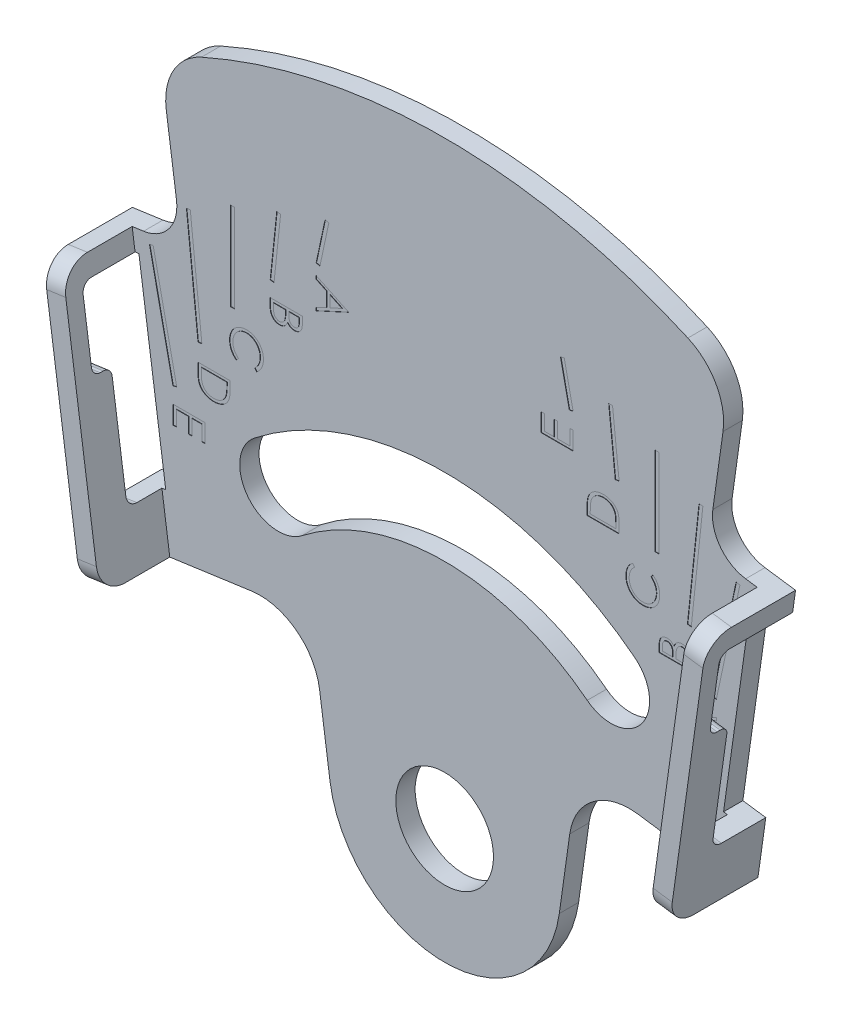
from build123d import *
from OCP.BRepFilletAPI import BRepFilletAPI_MakeFillet

# Parameters (mm, degrees)
SKETCH1_R          = 3.2131
EXTRUDE1_DEPTH     = 1.27
EXTRUDE2_DEPTH     = 4.5974
FILLET1_R          = 1.651
CUT_EXTRUDE1_DEPTH = 1.524
FILLET2_R1         = 0.635
FILLET2_R2         = 0.508
SKETCH4_W          = 0.254
SKETCH4_H          = 5.7912
CUT_EXTRUDE2_DEPTH = 0.0254
CUT_EXTRUDE3_DEPTH = 0.0254
CUT_EXTRUDE4_DEPTH = 0.0254


with BuildPart() as part:
    # Sketch1 → Extrude1 (new body)
    with BuildSketch(Plane.XY):
        with BuildLine():
            Line((21.821769044, 23.865251723), (19.809544328, 24.148051464))
            ThreePointArc((19.809544328, 24.148051464), (18.134509809, 25.1347222), (17.64776311, 27.016832035))
            Line((17.64776311, 27.016832035), (18.319649914, 31.79755506))
            ThreePointArc((18.319649914, 31.79755506), (17.8612339, 34.270332558), (16.006820778, 35.969133832))
            ThreePointArc((16.006820778, 35.969133832), (0, 39.37), (-16.006820778, 35.969133832))
            ThreePointArc((-16.006820778, 35.969133832), (-17.8612339, 34.270332558), (-18.319649914, 31.79755506))
            Line((-18.319649914, 31.79755506), (-17.64776311, 27.016832035))
            ThreePointArc((-17.64776311, 27.016832035), (-18.134509809, 25.1347222), (-19.809544328, 24.148051464))
            Line((-19.809544328, 24.148051464), (-21.821769044, 23.865251723))
            Line((-21.821769044, 23.865251723), (-19.347271309, 6.258285461))
            Line((-19.347271309, 6.258285461), (-12.706929747, 7.191524607))
            ThreePointArc((-12.706929747, 7.191524607), (-9.770838404, 6.432199756), (-8.231632056, 3.819145906))
            Line((-8.231632056, 3.819145906), (-7.545842684, -1.060499029))
            ThreePointArc((-7.545842684, -1.060499029), (0, -7.62), (7.545842684, -1.060499029))
            Line((7.545842684, -1.060499029), (8.231632056, 3.819145906))
            ThreePointArc((8.231632056, 3.819145906), (9.770838404, 6.432199756), (12.706929747, 7.191524607))
            Line((12.706929747, 7.191524607), (19.347271309, 6.258285461))
            Line((19.347271309, 6.258285461), (21.821769044, 23.865251723))
        make_face()
        Circle(SKETCH1_R, mode=Mode.SUBTRACT)
        with BuildLine():
            ThreePointArc((9.382680884, 12.009283885), (0, 15.24), (-9.382680884, 12.009283885))
            ThreePointArc((-9.382680884, 12.009283885), (-12.948008345, 12.447051052), (-12.510241179, 16.012378513))
            ThreePointArc((-12.510241179, 16.012378513), (0, 20.32), (12.510241179, 16.012378513))
            ThreePointArc((12.510241179, 16.012378513), (12.948008345, 12.447051052), (9.382680884, 12.009283885))
        make_face(mode=Mode.SUBTRACT)
    extrude(amount=EXTRUDE1_DEPTH)

    # Sketch2 → Extrude2 (add)
    with BuildSketch(Plane.XY.offset(1.27)):
        Polygon((-21.821769044, 23.865251723), (-19.347271309, 6.258285461), (-18.089630861, 6.435035299), (-20.564128596, 24.042001561), align=None)
        Polygon((19.347271309, 6.258285461), (21.821769044, 23.865251723), (20.564128596, 24.042001561), (18.089630861, 6.435035299), align=None)
    extrude(amount=EXTRUDE2_DEPTH)

    # Fillet1
    fillet1_edges = [part.edges().sort_by_distance(p)[0] for p in [
        (21.19294882, 23.953626642, 5.8674),
        (18.718451085, 6.34666038, 5.8674),
        (-21.19294882, 23.953626642, 5.8674),
        (-18.718451085, 6.34666038, 5.8674),
    ]]
    fillet(fillet1_edges, radius=FILLET1_R)

    # Sketch3 → Cut-Extrude1 (cut)
    with BuildSketch(Plane(origin=(18.110022441, -2.54519767, 0), x_dir=(0, 0, -1), z_dir=(0.9902680687415726, -0.13917310096005042, 0))):
        Polygon((0, 25.2984), (-4.7752, 25.2984), (-4.7752, 20.2184), (-3.556, 20.2184), (-3.556, 12.5984), (0, 12.5984), align=None)
    cut_extrude1 = extrude(amount=-CUT_EXTRUDE1_DEPTH, mode=Mode.SUBTRACT)

    # Mirror1: Cut-Extrude1 across plane
    add(cut_extrude1.mirror(Plane(origin=(0, 0, 0), x_dir=(0, 0, 1), z_dir=(1, 0, 0))), mode=Mode.SUBTRACT)

    # Fillet2: one fillet with a radius per group of edges: ONE call of the kernel's fillet builder (fillet() takes one radius for all edges)
    fillet2_edges_1 = [part.edges().sort_by_distance(p)[0] for p in [
        (21.002058995, 22.595374959, 4.7752),
        (19.234560613, 10.018970486, 3.556),
        (-21.002058995, 22.595374959, 4.7752),
        (-19.234560613, 10.018970486, 3.556),
    ]]
    fillet2_edges_2 = [part.edges().sort_by_distance(p)[0] for p in [
        (20.295059642, 17.56481317, 3.556),
        (20.295059642, 17.56481317, 4.7752),
        (-20.295059642, 17.56481317, 3.556),
        (-20.295059642, 17.56481317, 4.7752),
    ]]
    fillet2 = BRepFilletAPI_MakeFillet(part.part.solid().wrapped)
    for e in fillet2_edges_1:
        fillet2.Add(FILLET2_R1, e.wrapped)
    for e in fillet2_edges_2:
        fillet2.Add(FILLET2_R2, e.wrapped)
    add(Compound.cast(fillet2.Shape()), mode=Mode.REPLACE)

    # Sketch4 → Cut-Extrude2 (cut)
    with BuildSketch(Plane.XY.offset(1.27)):
        Polygon((-7.871224745, 30.765649695), (-8.455424745, 28.017204785), (-8.206975255, 27.964395215), (-7.622775255, 30.712840125), align=None)
        Polygon((-11.048304281, 29.648577686), (-11.480104281, 25.540275115), (-11.227495719, 25.513724885), (-10.795695719, 29.622027456), align=None)
        with Locations((-13.97, 25.6032)):
            Rectangle(SKETCH4_W, SKETCH4_H)
        Polygon((-16.991904281, 26.870870599), (-16.229904281, 19.620924885), (-15.977295719, 19.647475115), (-16.739295719, 26.897420829), align=None)
        Polygon((-19.428224745, 23.595149107), (-17.878824745, 16.305795215), (-17.630375255, 16.358604785), (-19.179775255, 23.647958676), align=None)
    cut_extrude2 = extrude(amount=-CUT_EXTRUDE2_DEPTH, mode=Mode.SUBTRACT)

    # Sketch5 → Cut-Extrude3 (cut)
    # profile 1 of 5: a face of its own
    with BuildSketch(Plane.XY.offset(1.27)):
        Polygon((-6.338758079, 26.260368492), (-8.455424745, 25.283445415), (-8.455424745, 25.489939138), (-7.777005942, 25.802859811), (-7.777005942, 26.762398406), (-8.455424745, 27.084223326), (-8.455424745, 27.291565073), (-6.338758079, 26.287505244), align=None)
        Polygon((-6.751321513, 26.276056927), (-7.559911925, 26.659363551), (-7.559911925, 25.902926585), align=None, mode=Mode.SUBTRACT)
    # profile 2 of 5: a face of its own
    with BuildSketch(Plane.XY.offset(1.27)):
        with BuildLine():
            Line((-9.363437614, 24.527078991), (-9.363437614, 24.114091544))
            add(Edge.make_bspline(
                [(-9.363437614, 24.114091544), (-9.363543901, 24.093875274), (-9.363749912, 24.054691111), (-9.366944949, 23.997710782), (-9.371301454, 23.944341263), (-9.378213938, 23.894567077), (-9.38655468, 23.848411224), (-9.396655302, 23.805734605), (-9.408766635, 23.766672929), (-9.428026053, 23.720038084), (-9.456645302, 23.666867018), (-9.498935434, 23.609294656), (-9.55066221, 23.560064474), (-9.609011244, 23.517618463), (-9.673198116, 23.483872071), (-9.741692958, 23.459458258), (-9.813612297, 23.444001829), (-9.862986981, 23.442412252), (-9.887940151, 23.441608905)],
                knots=[0, 0, 0, 0, 1.001505555, 1.941167018, 2.826882275, 3.653841531, 4.429895133, 5.150066043, 5.825578002, 6.45369114, 7.647487171, 8.808567382, 9.977351308, 11.170798116, 12.373658725, 13.556498008, 14.765093433, 16, 16, 16, 16], degree=3))
            add(Edge.make_bspline(
                [(-9.887940151, 23.441608905), (-9.911319705, 23.442257264), (-9.957262733, 23.443531351), (-10.024351251, 23.456129541), (-10.088476908, 23.474886448), (-10.148849168, 23.502115936), (-10.204692117, 23.537141483), (-10.255673883, 23.579290687), (-10.300558964, 23.629474823), (-10.325547559, 23.667134352), (-10.338240632, 23.686263686)],
                knots=[0, 0, 0, 0, 1.044266239, 2.052081639, 3.041743201, 4.026043445, 5.00270663, 5.980942822, 6.97441044, 8, 8, 8, 8], degree=3))
            add(Edge.make_bspline(
                [(-10.338240632, 23.686263686), (-10.347465198, 23.662214067), (-10.365114077, 23.616201189), (-10.396486869, 23.55283586), (-10.430224884, 23.498023445), (-10.467263493, 23.45170361), (-10.507686428, 23.412686317), (-10.550684242, 23.377647979), (-10.598373779, 23.348293707), (-10.649397111, 23.323075913), (-10.703396132, 23.303229774), (-10.760123883, 23.289187328), (-10.818946046, 23.280558928), (-10.859039327, 23.27938236), (-10.879279628, 23.278788392)],
                knots=[0, 0, 0, 0, 1.272302504, 2.434229863, 3.488457646, 4.447234501, 5.35599188, 6.26022912, 7.18267843, 8.11661068, 9.06895546, 10.019249207, 11.000057067, 12, 12, 12, 12], degree=3))
            add(Edge.make_bspline(
                [(-10.879279628, 23.278788392), (-10.899942333, 23.279379337), (-10.940596785, 23.280542037), (-11.000321802, 23.289114896), (-11.057390024, 23.303644422), (-11.112207215, 23.323608783), (-11.164463091, 23.349812835), (-11.214812111, 23.381015031), (-11.261913013, 23.418992058), (-11.306885908, 23.461322831), (-11.347298138, 23.509266984), (-11.383276244, 23.560987468), (-11.413000285, 23.617228193), (-11.437657103, 23.677117014), (-11.456766012, 23.741051895), (-11.470032302, 23.808795779), (-11.478991958, 23.880363389), (-11.479727215, 23.929476307), (-11.480104281, 23.954663125)],
                knots=[0, 0, 0, 0, 0.978404568, 1.925038397, 2.85041836, 3.763147166, 4.682162379, 5.614488577, 6.562659439, 7.54271123, 8.535210642, 9.526693784, 10.520907202, 11.541451354, 12.589717429, 13.675358278, 14.807842563, 16, 16, 16, 16], degree=3))
            Line((-11.480104281, 23.954663125), (-11.480104281, 24.527078991))
            Line((-11.480104281, 24.527078991), (-9.363437614, 24.527078991))
        make_face()
        with BuildLine():
            Line((-9.580531631, 24.337121726), (-10.258950435, 24.337121726))
            Line((-10.258950435, 24.337121726), (-10.258950435, 24.209494188))
            add(Edge.make_bspline(
                [(-10.258950435, 24.209494188), (-10.258710589, 24.190837844), (-10.258247158, 24.154789985), (-10.256877809, 24.102448271), (-10.253211478, 24.053984273), (-10.249333728, 24.009230994), (-10.243362786, 23.96848839), (-10.236056031, 23.931620064), (-10.228396025, 23.898294825), (-10.21533244, 23.859880972), (-10.196221582, 23.816320173), (-10.165865692, 23.77017786), (-10.13069178, 23.7288392), (-10.089357172, 23.69432194), (-10.044228937, 23.665839167), (-9.995303052, 23.646831001), (-9.944489568, 23.633348758), (-9.909514088, 23.632166453), (-9.891756257, 23.63156617)],
                knots=[0, 0, 0, 0, 1.156481963, 2.23455883, 3.244418989, 4.168404366, 5.01828131, 5.794834307, 6.498111525, 7.13526334, 8.307595709, 9.435046769, 10.546766856, 11.659452936, 12.760769924, 13.837671619, 14.902137667, 16, 16, 16, 16], degree=3))
            add(Edge.make_bspline(
                [(-9.891756257, 23.63156617), (-9.880002758, 23.631866397), (-9.856946984, 23.632455324), (-9.823466439, 23.637815263), (-9.791575037, 23.645592585), (-9.762006262, 23.657743136), (-9.733919682, 23.672435664), (-9.70856281, 23.691547976), (-9.684546448, 23.713132256), (-9.662752414, 23.738480893), (-9.643224875, 23.767471146), (-9.626042354, 23.800379239), (-9.612488289, 23.837598112), (-9.600329572, 23.878283869), (-9.591892747, 23.923087649), (-9.584838438, 23.971571659), (-9.581252538, 24.024147202), (-9.580777293, 24.060520563), (-9.580531631, 24.079322581)],
                knots=[0, 0, 0, 0, 0.911752476, 1.788502045, 2.626783689, 3.45400582, 4.26402138, 5.080402872, 5.911472738, 6.767166405, 7.66795952, 8.620018292, 9.640966946, 10.73819047, 11.913090943, 13.176185384, 14.540321519, 16, 16, 16, 16], degree=3))
            Line((-9.580531631, 24.079322581), (-9.580531631, 24.337121726))
        make_face(mode=Mode.SUBTRACT)
        with BuildLine():
            Line((-10.476044452, 24.337121726), (-11.263010264, 24.337121726))
            Line((-11.263010264, 24.337121726), (-11.263010264, 24.066602228))
            add(Edge.make_bspline(
                [(-11.263010264, 24.066602228), (-11.262778998, 24.047238305), (-11.262333265, 24.009916897), (-11.260862246, 23.956033145), (-11.257586505, 23.906225942), (-11.252246174, 23.860466626), (-11.246697104, 23.818352391), (-11.239016923, 23.780301642), (-11.230285486, 23.746256046), (-11.216773174, 23.706784331), (-11.195817389, 23.662308105), (-11.164014742, 23.614411688), (-11.126625688, 23.571402671), (-11.082807094, 23.535298756), (-11.035522587, 23.505485558), (-10.985019479, 23.484575823), (-10.932838472, 23.471131163), (-10.897168516, 23.469542427), (-10.879279628, 23.468745657)],
                knots=[0, 0, 0, 0, 1.159821618, 2.235403267, 3.228114831, 4.14795534, 4.994323282, 5.771256229, 6.471395042, 7.097801288, 8.267864287, 9.404187171, 10.531774336, 11.667624178, 12.792825787, 13.866573821, 14.930062559, 16, 16, 16, 16], degree=3))
            add(Edge.make_bspline(
                [(-10.879279628, 23.468745657), (-10.868094113, 23.468908515), (-10.845903507, 23.469231602), (-10.813318368, 23.474287376), (-10.781613369, 23.48134051), (-10.751267933, 23.491554055), (-10.721788277, 23.504432508), (-10.69368789, 23.520594477), (-10.666294881, 23.53925849), (-10.631703718, 23.568455172), (-10.591835258, 23.610882178), (-10.552806893, 23.671184494), (-10.52132995, 23.739746765), (-10.507965088, 23.789474959), (-10.501061145, 23.815163259)],
                knots=[0, 0, 0, 0, 0.723503378, 1.435336582, 2.130201219, 2.824764462, 3.504949994, 4.209866579, 4.920640069, 5.648298893, 7.13757748, 8.670694625, 10.280166878, 12, 12, 12, 12], degree=3))
            add(Edge.make_bspline(
                [(-10.501061145, 23.815163259), (-10.498971501, 23.825461798), (-10.494440723, 23.847791154), (-10.489661146, 23.88420259), (-10.48537371, 23.925910813), (-10.482285558, 23.972737555), (-10.478970481, 24.024869052), (-10.477727125, 24.082288556), (-10.476209544, 24.14503666), (-10.47610089, 24.188574958), (-10.476044452, 24.211190235)],
                knots=[0, 0, 0, 0, 0.634452549, 1.375623993, 2.216454381, 3.166361212, 4.209414599, 5.370755378, 6.634280627, 8, 8, 8, 8], degree=3))
            Line((-10.476044452, 24.211190235), (-10.476044452, 24.337121726))
        make_face(mode=Mode.SUBTRACT)
    # profile 3 of 5: a face of its own
    with BuildSketch(Plane.XY.offset(1.27)):
        with BuildLine():
            Line((-12.368728098, 19.853290674), (-12.495931624, 20.01950328))
            add(Edge.make_bspline(
                [(-12.495931624, 20.01950328), (-12.481800776, 20.031360175), (-12.453729593, 20.054914107), (-12.414311488, 20.092808006), (-12.377381544, 20.132299952), (-12.342763836, 20.173374849), (-12.311668935, 20.21677203), (-12.28247641, 20.261440228), (-12.256309731, 20.308126665), (-12.224582115, 20.372686047), (-12.191473726, 20.457139746), (-12.163713201, 20.563453767), (-12.146041347, 20.674434289), (-12.144127371, 20.750149028), (-12.143153846, 20.788660599)],
                knots=[0, 0, 0, 0, 0.757959112, 1.505699292, 2.245454638, 2.979532153, 3.711538275, 4.438200793, 5.171680507, 5.909471876, 7.393775596, 8.890124382, 10.418191784, 12, 12, 12, 12], degree=3))
            add(Edge.make_bspline(
                [(-12.143153846, 20.788660599), (-12.14339925, 20.809877384), (-12.143887779, 20.852114042), (-12.150287506, 20.914800496), (-12.159385989, 20.976435128), (-12.172557933, 21.03678874), (-12.189706608, 21.095741498), (-12.209817428, 21.153742277), (-12.234843301, 21.210107983), (-12.262481038, 21.265516963), (-12.293706601, 21.318600035), (-12.327754856, 21.368836383), (-12.364291624, 21.415996502), (-12.403222593, 21.460211072), (-12.445031598, 21.500995186), (-12.489226803, 21.539002469), (-12.536340155, 21.573547942), (-12.58548808, 21.605480499), (-12.636742818, 21.633894763), (-12.689781933, 21.658431856), (-12.744402638, 21.679462185), (-12.800716826, 21.69625724), (-12.858502887, 21.709504549), (-12.917883457, 21.718656392), (-12.978743275, 21.724998547), (-13.019993614, 21.725482583), (-13.040786725, 21.725726571)],
                knots=[0, 0, 0, 0, 1.055000685, 2.100209969, 3.131349012, 4.153242145, 5.170189196, 6.184191144, 7.204341339, 8.235672124, 9.263040994, 10.265373269, 11.252624173, 12.22887325, 13.193405896, 14.155809299, 15.126090485, 16.097288279, 17.069732292, 18.038585918, 19.002221264, 19.978698174, 20.959418239, 21.948869816, 22.966084182, 24, 24, 24, 24], degree=3))
            add(Edge.make_bspline(
                [(-13.040786725, 21.725726571), (-13.072071857, 21.724963471), (-13.133496063, 21.723465225), (-13.223466861, 21.710131233), (-13.309657935, 21.68986863), (-13.391530506, 21.659500162), (-13.470094132, 21.622053879), (-13.544019534, 21.574736938), (-13.614423838, 21.519935508), (-13.679643144, 21.456874311), (-13.739220492, 21.387686032), (-13.791683939, 21.313452771), (-13.835417225, 21.234359416), (-13.871809345, 21.151279264), (-13.899783652, 21.063572995), (-13.919477193, 20.971398329), (-13.932323655, 20.874955741), (-13.933553552, 20.809055199), (-13.934179487, 20.775516234)],
                knots=[0, 0, 0, 0, 1.029171465, 2.020641659, 2.987623507, 3.938342917, 4.889210282, 5.84687017, 6.821220943, 7.821438502, 8.827599549, 9.822697543, 10.807740252, 11.797342354, 12.80366471, 13.83203677, 14.896651826, 16, 16, 16, 16], degree=3))
            add(Edge.make_bspline(
                [(-13.934179487, 20.775516234), (-13.933158178, 20.738563656), (-13.931147996, 20.665832141), (-13.914118355, 20.559171478), (-13.886506185, 20.457066039), (-13.847863156, 20.359510332), (-13.797628434, 20.266779379), (-13.736730194, 20.178728065), (-13.664589155, 20.095282068), (-13.609505549, 20.045104197), (-13.581401709, 20.01950328)],
                knots=[0, 0, 0, 0, 1.028121516, 2.023589091, 2.998037872, 3.967518031, 4.937445131, 5.927275754, 6.942489185, 8, 8, 8, 8], degree=3))
            Line((-13.581401709, 20.01950328), (-13.7073332, 19.853290674))
            add(Edge.make_bspline(
                [(-13.7073332, 19.853290674), (-13.724592198, 19.866666846), (-13.759027524, 19.89335512), (-13.807572359, 19.93657047), (-13.853235958, 19.982094328), (-13.89564039, 20.030270727), (-13.935670892, 20.080523477), (-13.971985474, 20.133737755), (-14.005690336, 20.188994448), (-14.036143989, 20.246615267), (-14.063449031, 20.306411037), (-14.086500703, 20.368319528), (-14.106643564, 20.431816248), (-14.123105316, 20.496933175), (-14.135974479, 20.563887847), (-14.144572563, 20.63245054), (-14.150464488, 20.702765983), (-14.151001413, 20.750204386), (-14.151273504, 20.774244199)],
                knots=[0, 0, 0, 0, 0.986756325, 1.968786143, 2.935506311, 3.899499537, 4.868307269, 5.8376204, 6.809456583, 7.792545619, 8.781780509, 9.778496008, 10.776623214, 11.79151764, 12.812666265, 13.856269958, 14.913646641, 16, 16, 16, 16], degree=3))
            add(Edge.make_bspline(
                [(-14.151273504, 20.774244199), (-14.151115061, 20.797009655), (-14.15080176, 20.842025525), (-14.145726496, 20.908488103), (-14.138802132, 20.973191326), (-14.128375957, 21.035950266), (-14.116072475, 21.097107403), (-14.099579858, 21.156108328), (-14.081104886, 21.213533622), (-14.059390918, 21.269152571), (-14.034888274, 21.323012485), (-14.007195284, 21.374939647), (-13.976544823, 21.424910175), (-13.943612507, 21.473415358), (-13.90734052, 21.519738659), (-13.868232603, 21.564281505), (-13.826420567, 21.607293669), (-13.796270251, 21.633904817), (-13.781111245, 21.647284397)],
                knots=[0, 0, 0, 0, 1.114604814, 2.203992996, 3.262667896, 4.300477797, 5.318619304, 6.316056647, 7.298880507, 8.271930387, 9.238335007, 10.195173496, 11.151986948, 12.108099108, 13.064862484, 14.031167946, 15.010108607, 16, 16, 16, 16], degree=3))
            add(Edge.make_bspline(
                [(-13.781111245, 21.647284397), (-13.754779192, 21.668714524), (-13.702432991, 21.711316055), (-13.617593374, 21.765820635), (-13.529014981, 21.812476538), (-13.436232453, 21.850199118), (-13.339453985, 21.879688962), (-13.238630793, 21.900118542), (-13.133857038, 21.913394036), (-13.062593837, 21.914912163), (-13.026370326, 21.915683836)],
                knots=[0, 0, 0, 0, 0.994628077, 1.977248131, 2.950237994, 3.925870899, 4.908910175, 5.911660606, 6.938484602, 8, 8, 8, 8], degree=3))
            add(Edge.make_bspline(
                [(-13.026370326, 21.915683836), (-12.988298859, 21.914739107), (-12.913395624, 21.912880413), (-12.803442927, 21.897219187), (-12.698252052, 21.871719686), (-12.597418249, 21.836606703), (-12.501518452, 21.790283289), (-12.410147635, 21.734205052), (-12.323380405, 21.66782424), (-12.242326089, 21.591974535), (-12.168220932, 21.508774668), (-12.10302333, 21.419683008), (-12.04876573, 21.324866956), (-12.003410872, 21.225372908), (-11.968549706, 21.120455355), (-11.944145634, 21.010338276), (-11.928955759, 20.89522855), (-11.927035514, 20.816692702), (-11.926059829, 20.77678827)],
                knots=[0, 0, 0, 0, 1.032901378, 2.032168977, 3.007206631, 3.966850309, 4.924221947, 5.891988639, 6.871730993, 7.884084801, 8.900290346, 9.89161143, 10.874607481, 11.860025555, 12.854717796, 13.869097222, 14.917278314, 16, 16, 16, 16], degree=3))
            add(Edge.make_bspline(
                [(-11.926059829, 20.77678827), (-11.92635119, 20.752468041), (-11.92692791, 20.704328599), (-11.932559068, 20.633116971), (-11.941929494, 20.56378312), (-11.954767612, 20.49615937), (-11.97050284, 20.430000505), (-11.99110147, 20.365985265), (-12.01502153, 20.303765062), (-12.041868365, 20.243293298), (-12.07256045, 20.185227886), (-12.105895271, 20.129579395), (-12.142642307, 20.077019121), (-12.181586701, 20.026558401), (-12.224185229, 19.979333267), (-12.269050636, 19.933994981), (-12.317514236, 19.892109696), (-12.351625561, 19.866254035), (-12.368728098, 19.853290674)],
                knots=[0, 0, 0, 0, 1.096705196, 2.170817488, 3.219277236, 4.250701065, 5.274195539, 6.284202015, 7.28098643, 8.279664616, 9.266225751, 10.241373748, 11.203306326, 12.157093976, 13.114198862, 14.069774147, 15.032234603, 16, 16, 16, 16], degree=3))
        make_face()
    # profile 4 of 5: a face of its own
    with BuildSketch(Plane.XY.offset(1.27)):
        with BuildLine():
            Line((-16.229904281, 18.473822094), (-14.113237614, 18.473822094))
            Line((-14.113237614, 18.473822094), (-14.113237614, 18.046418248))
            add(Edge.make_bspline(
                [(-14.113237614, 18.046418248), (-14.113504534, 18.009244068), (-14.114020223, 17.937423746), (-14.117308643, 17.833640111), (-14.123067125, 17.737750701), (-14.131616833, 17.649809971), (-14.141878878, 17.569676638), (-14.154929638, 17.497479044), (-14.170278215, 17.433100187), (-14.183369175, 17.393506841), (-14.189559729, 17.374783632)],
                knots=[0, 0, 0, 0, 1.314317071, 2.539253741, 3.67075822, 4.709970291, 5.662644612, 6.526156501, 7.303037452, 8, 8, 8, 8], degree=3))
            add(Edge.make_bspline(
                [(-14.189559729, 17.374783632), (-14.198891643, 17.350293972), (-14.217343853, 17.301869996), (-14.252151559, 17.232922606), (-14.291590525, 17.168017155), (-14.335709364, 17.106800576), (-14.385769881, 17.050689725), (-14.439598896, 16.997422431), (-14.499396015, 16.949389905), (-14.563130944, 16.904664574), (-14.631450247, 16.865529179), (-14.702967352, 16.831016306), (-14.777548444, 16.801548338), (-14.855736361, 16.778555208), (-14.936780506, 16.759558966), (-15.02129438, 16.74681294), (-15.10878529, 16.738346271), (-15.16815823, 16.737499569), (-15.198283688, 16.737069957)],
                knots=[0, 0, 0, 0, 0.98467389, 1.947018643, 2.898343565, 3.837828625, 4.779009928, 5.722093987, 6.681368302, 7.658573986, 8.646467994, 9.637429229, 10.641859304, 11.657149908, 12.698561448, 13.768651538, 14.867827761, 16, 16, 16, 16], degree=3))
            add(Edge.make_bspline(
                [(-15.198283688, 16.737069957), (-15.224446348, 16.737450589), (-15.276002603, 16.738200664), (-15.351986697, 16.744927581), (-15.425710753, 16.75472381), (-15.496850983, 16.769820965), (-15.56588662, 16.788371728), (-15.632489822, 16.81126909), (-15.696709409, 16.838404681), (-15.758022267, 16.869887416), (-15.816326965, 16.904312389), (-15.870620181, 16.942057358), (-15.921934502, 16.980956389), (-15.967955384, 17.024008847), (-16.011314913, 17.068247938), (-16.049670295, 17.116019576), (-16.084692259, 17.165767391), (-16.116125172, 17.218449602), (-16.143396706, 17.275328922), (-16.166759744, 17.337181678), (-16.18599686, 17.404339136), (-16.202072503, 17.476698359), (-16.214817322, 17.554401132), (-16.223360992, 17.637518731), (-16.229138079, 17.725924888), (-16.229643921, 17.786630433), (-16.229904281, 17.817875913)],
                knots=[0, 0, 0, 0, 1.105818345, 2.179130549, 3.222742436, 4.24813173, 5.251184997, 6.243232575, 7.223185975, 8.195898781, 9.155064964, 10.083206407, 10.990357329, 11.874224667, 12.744762365, 13.607037788, 14.46074101, 15.315384698, 16.197310979, 17.123950979, 18.107232398, 19.148086642, 20.256146639, 21.433991621, 22.679261309, 24, 24, 24, 24], degree=3))
            Line((-16.229904281, 17.817875913), (-16.229904281, 18.473822094))
        make_face()
        with BuildLine():
            Line((-16.012810264, 18.283864829), (-16.012810264, 18.040906095))
            add(Edge.make_bspline(
                [(-16.012810264, 18.040906095), (-16.012660224, 18.005994175), (-16.012371644, 17.938845769), (-16.009839383, 17.842290694), (-16.00570164, 17.754068392), (-15.999910998, 17.674166337), (-15.992249502, 17.602629641), (-15.983707299, 17.539308802), (-15.973065031, 17.484411384), (-15.963418498, 17.451192153), (-15.958960771, 17.435841324)],
                knots=[0, 0, 0, 0, 1.375205317, 2.645023457, 3.804390687, 4.853969522, 5.800190428, 6.637939096, 7.370582563, 8, 8, 8, 8], degree=3))
            add(Edge.make_bspline(
                [(-15.958960771, 17.435841324), (-15.952156764, 17.416519764), (-15.938711265, 17.378338137), (-15.914176203, 17.323382626), (-15.885149244, 17.272103023), (-15.852693373, 17.223643804), (-15.816305942, 17.178318761), (-15.775876819, 17.136328966), (-15.731853115, 17.097375983), (-15.684069916, 17.061885918), (-15.632836152, 17.030173676), (-15.578804071, 17.002532944), (-15.522104078, 16.97908019), (-15.462531815, 16.960009712), (-15.400143431, 16.945231189), (-15.33510306, 16.934716443), (-15.26739041, 16.928179756), (-15.221336717, 16.927416375), (-15.197859676, 16.927027222)],
                knots=[0, 0, 0, 0, 0.998463025, 1.973077781, 2.929496817, 3.867873318, 4.813809365, 5.759268434, 6.706333209, 7.676553387, 8.657505312, 9.640584699, 10.632319813, 11.645628493, 12.686877747, 13.755137172, 14.855624085, 16, 16, 16, 16], degree=3))
            add(Edge.make_bspline(
                [(-15.197859676, 16.927027222), (-15.173104815, 16.927337969), (-15.124473671, 16.927948436), (-15.053115292, 16.935608685), (-14.984494131, 16.946826811), (-14.918560783, 16.96296321), (-14.855401031, 16.983810046), (-14.794658047, 17.008754975), (-14.737113536, 17.039042034), (-14.682280118, 17.073330188), (-14.630988211, 17.111824919), (-14.583838727, 17.154355468), (-14.540743837, 17.200473376), (-14.501634927, 17.249966099), (-14.467207496, 17.303525629), (-14.436581391, 17.360245633), (-14.410559631, 17.42092509), (-14.396724381, 17.463145943), (-14.389693276, 17.484602676)],
                knots=[0, 0, 0, 0, 1.122272916, 2.204715076, 3.251197285, 4.274229216, 5.279697671, 6.265416158, 7.248880903, 8.225321784, 9.195852973, 10.153576302, 11.101466393, 12.055578741, 13.010401466, 13.985536859, 14.976245305, 16, 16, 16, 16], degree=3))
            add(Edge.make_bspline(
                [(-14.389693276, 17.484602676), (-14.38478477, 17.502353131), (-14.374347939, 17.540095469), (-14.362963071, 17.601684097), (-14.352921302, 17.670998973), (-14.344419535, 17.74834784), (-14.338319108, 17.833642527), (-14.333740265, 17.926948634), (-14.330651968, 18.02830649), (-14.330441084, 18.098569261), (-14.330331631, 18.135036704)],
                knots=[0, 0, 0, 0, 0.674548936, 1.434276114, 2.292660221, 3.240891867, 4.284742987, 5.42552168, 6.663806718, 8, 8, 8, 8], degree=3))
            Line((-14.330331631, 18.135036704), (-14.330331631, 18.283864829))
            Line((-14.330331631, 18.283864829), (-16.012810264, 18.283864829))
        make_face(mode=Mode.SUBTRACT)
    # profile 5 of 5: a face of its own
    with BuildSketch(Plane.XY.offset(1.27)):
        Polygon((-15.762158079, 15.257465772), (-15.762158079, 14.063448678), (-15.979252096, 14.063448678), (-15.979252096, 15.067508507), (-16.630534147, 15.067508507), (-16.630534147, 14.063448678), (-16.847628164, 14.063448678), (-16.847628164, 15.067508507), (-17.661730728, 15.067508507), (-17.661730728, 14.063448678), (-17.878824745, 14.063448678), (-17.878824745, 15.257465772), align=None)
    extrude(amount=-CUT_EXTRUDE3_DEPTH, mode=Mode.SUBTRACT)

    # Mirror2: Cut-Extrude2 across plane
    add(cut_extrude2.mirror(Plane(origin=(0, 0, 0), x_dir=(0, 0, 1), z_dir=(1, 0, 0))), mode=Mode.SUBTRACT)

    # Sketch6 → Cut-Extrude4 (cut)
    # profile 1 of 5: a face of its own
    with BuildSketch(Plane.XY.offset(1.27)):
        Polygon((6.338758079, 25.745920499), (6.338758079, 26.939937593), (6.555852096, 26.939937593), (6.555852096, 25.935877764), (7.207134147, 25.935877764), (7.207134147, 26.939937593), (7.424228164, 26.939937593), (7.424228164, 25.935877764), (8.238330728, 25.935877764), (8.238330728, 26.939937593), (8.455424745, 26.939937593), (8.455424745, 25.745920499), align=None)
    # profile 2 of 5: a face of its own
    with BuildSketch(Plane.XY.offset(1.27)):
        with BuildLine():
            Line((11.480104281, 22.540913257), (9.363437614, 22.540913257))
            Line((9.363437614, 22.540913257), (9.363437614, 22.968317104))
            add(Edge.make_bspline(
                [(9.363437614, 22.968317104), (9.363705264, 23.005491206), (9.364222361, 23.077311378), (9.367501012, 23.181096049), (9.37330096, 23.27712242), (9.381749197, 23.365074673), (9.392122699, 23.445194263), (9.405125324, 23.517256849), (9.420479122, 23.58163505), (9.433569466, 23.621228474), (9.439759729, 23.639951719)],
                knots=[0, 0, 0, 0, 1.314313732, 2.53924729, 3.670748893, 4.714932338, 5.66265055, 6.526160246, 7.303039223, 8, 8, 8, 8], degree=3))
            add(Edge.make_bspline(
                [(9.439759729, 23.639951719), (9.449088726, 23.6644436), (9.467535169, 23.712871968), (9.502385216, 23.781787114), (9.541709646, 23.846884105), (9.586413426, 23.907643929), (9.635912798, 23.964219039), (9.68985414, 24.017251547), (9.749435735, 24.065433934), (9.813597066, 24.109516643), (9.881516046, 24.149273652), (9.953081442, 24.183828539), (10.027924861, 24.212527096), (10.105839512, 24.236350567), (10.186996352, 24.255126296), (10.271489981, 24.267936318), (10.358986442, 24.276385441), (10.418358617, 24.277234558), (10.448483688, 24.277665394)],
                knots=[0, 0, 0, 0, 0.984741985, 1.947153288, 2.898543998, 3.841229145, 4.778974371, 5.722123648, 6.681464302, 7.655713756, 8.646344578, 9.637374342, 10.639946623, 11.656849581, 12.698333139, 13.76849723, 14.867749466, 16, 16, 16, 16], degree=3))
            add(Edge.make_bspline(
                [(10.448483688, 24.277665394), (10.474646437, 24.277285018), (10.526202866, 24.276535448), (10.602185696, 24.269804866), (10.675914367, 24.260022028), (10.74703786, 24.244876308), (10.816179046, 24.226489823), (10.882602006, 24.202926532), (10.946912481, 24.175929958), (11.008254035, 24.144462199), (11.06633207, 24.109868849), (11.121122029, 24.072976078), (11.171408103, 24.032947188), (11.218508017, 23.990966912), (11.261163548, 23.946022902), (11.30015225, 23.898662345), (11.334821368, 23.848701185), (11.365715693, 23.795830148), (11.393343633, 23.739343127), (11.41638865, 23.677463322), (11.436347987, 23.610483842), (11.452225641, 23.538022722), (11.465031082, 23.460338409), (11.473556995, 23.377215403), (11.479339174, 23.288810796), (11.479844293, 23.228105031), (11.480104281, 23.196859438)],
                knots=[0, 0, 0, 0, 1.106010661, 2.179509527, 3.223302912, 4.248870533, 5.252098245, 6.246278179, 7.226402005, 8.199283979, 9.158616973, 10.083547221, 10.989831858, 11.874256832, 12.749262829, 13.607058236, 14.46581075, 15.317568432, 16.194266721, 17.121067875, 18.106207572, 19.147242834, 20.255495536, 21.43354536, 22.679031616, 24, 24, 24, 24], degree=3))
            Line((11.480104281, 23.196859438), (11.480104281, 22.540913257))
        make_face()
        with BuildLine():
            Line((11.263010264, 22.730870522), (11.263010264, 22.973829256))
            add(Edge.make_bspline(
                [(11.263010264, 22.973829256), (11.262860224, 23.008741176), (11.262571644, 23.075889583), (11.260039383, 23.172444657), (11.25590164, 23.260666959), (11.250110998, 23.340569014), (11.242449502, 23.41210571), (11.233907299, 23.475426549), (11.223265031, 23.530323967), (11.213618498, 23.563543198), (11.209160771, 23.578894027)],
                knots=[0, 0, 0, 0, 1.375205317, 2.645023457, 3.804390687, 4.853969522, 5.800190428, 6.637939096, 7.370582563, 8, 8, 8, 8], degree=3))
            add(Edge.make_bspline(
                [(11.209160771, 23.578894027), (11.202356259, 23.598215181), (11.188909759, 23.636396004), (11.164382012, 23.691357393), (11.135328066, 23.742615308), (11.103032158, 23.791062408), (11.06635669, 23.836013799), (11.026093624, 23.877993373), (10.982059009, 23.916949734), (10.934324248, 23.95228285), (10.883406968, 23.984286521), (10.829217117, 24.011760331), (10.772516523, 24.03568642), (10.712846162, 24.054631549), (10.650643386, 24.069568953), (10.585585647, 24.080039239), (10.517730515, 24.08653935), (10.471536502, 24.087314288), (10.448059676, 24.087708129)],
                knots=[0, 0, 0, 0, 0.998590647, 1.973329978, 2.929871262, 3.868367705, 4.809062953, 5.754642869, 6.701828697, 7.672172887, 8.647399344, 9.630604387, 10.631475358, 11.644913558, 12.679592956, 13.747988925, 14.855477812, 16, 16, 16, 16], degree=3))
            add(Edge.make_bspline(
                [(10.448059676, 24.087708129), (10.423304666, 24.087397713), (10.374673231, 24.086787896), (10.303316954, 24.079122956), (10.234688179, 24.067921825), (10.168782318, 24.051724072), (10.105470791, 24.031083017), (10.045103754, 24.0053234), (9.987043666, 23.975891683), (9.932630598, 23.94087395), (9.881169527, 23.902522615), (9.834025364, 23.859960755), (9.791090715, 23.81386457), (9.751696941, 23.764736828), (9.717428908, 23.711192963), (9.686775534, 23.654494302), (9.660761162, 23.593809063), (9.646924897, 23.551589004), (9.639893276, 23.530132675)],
                knots=[0, 0, 0, 0, 1.122418816, 2.205001699, 3.251619955, 4.274784885, 5.280384055, 6.268708349, 7.249350384, 8.229342522, 9.199999885, 10.157847722, 11.105861043, 12.055065948, 13.010012805, 13.98527497, 14.976112212, 16, 16, 16, 16], degree=3))
            add(Edge.make_bspline(
                [(9.639893276, 23.530132675), (9.63498477, 23.51238222), (9.624547939, 23.474639882), (9.613163071, 23.413051254), (9.603121302, 23.343736378), (9.594619535, 23.266387511), (9.588519108, 23.181092824), (9.583940265, 23.087786717), (9.580851968, 22.986428861), (9.580641084, 22.916166091), (9.580531631, 22.879698647)],
                knots=[0, 0, 0, 0, 0.674548936, 1.434276114, 2.292660221, 3.240891867, 4.284742987, 5.42552168, 6.663806718, 8, 8, 8, 8], degree=3))
            Line((9.580531631, 22.879698647), (9.580531631, 22.730870522))
            Line((9.580531631, 22.730870522), (11.263010264, 22.730870522))
        make_face(mode=Mode.SUBTRACT)
    # profile 3 of 5: a face of its own
    with BuildSketch(Plane.XY.offset(1.27)):
        with BuildLine():
            Line((12.368728098, 21.311706095), (12.495931624, 21.145493488))
            add(Edge.make_bspline(
                [(12.495931624, 21.145493488), (12.481800962, 21.133636472), (12.453730151, 21.110082299), (12.414309299, 21.072190186), (12.37738963, 21.032691558), (12.34273393, 20.991641371), (12.311735082, 20.948089628), (12.281978872, 20.903695775), (12.255926286, 20.856846785), (12.224099794, 20.792392553), (12.191612987, 20.707746656), (12.163671529, 20.601559632), (12.146052288, 20.490558113), (12.14413106, 20.414846269), (12.143153846, 20.37633617)],
                knots=[0, 0, 0, 0, 0.75789156, 1.505565099, 2.245254514, 2.979266606, 3.711207489, 4.440978832, 5.174393176, 5.91211879, 7.394186119, 8.890401545, 10.418332761, 12, 12, 12, 12], degree=3))
            add(Edge.make_bspline(
                [(12.143153846, 20.37633617), (12.143398147, 20.355119127), (12.143884482, 20.312881955), (12.150300477, 20.250199307), (12.159318209, 20.188687128), (12.172698762, 20.128385432), (12.189615535, 20.069370976), (12.209829954, 20.011257954), (12.234839779, 19.954887725), (12.262482421, 19.899480541), (12.293704631, 19.846394882), (12.327761169, 19.796166849), (12.364268755, 19.748976697), (12.403372216, 19.704797858), (12.444866051, 19.663545541), (12.489215128, 19.625738848), (12.535945342, 19.590872652), (12.585095499, 19.559145662), (12.636207842, 19.530584003), (12.689574192, 19.50656809), (12.744280808, 19.485592753), (12.800715522, 19.468734025), (12.85850324, 19.45549371), (12.91788336, 19.446339965), (12.9787433, 19.439998327), (13.019993623, 19.439514222), (13.040786725, 19.439270198)],
                knots=[0, 0, 0, 0, 1.054877232, 2.099964208, 3.13098259, 4.145888998, 5.169474743, 6.183358035, 7.203388855, 8.234598956, 9.261847606, 10.264062591, 11.251197969, 12.227332808, 13.196685059, 14.158975844, 15.123498106, 16.094582253, 17.066912473, 18.032714859, 19.002806091, 19.979168736, 20.95977404, 21.949109834, 22.966205168, 24, 24, 24, 24], degree=3))
            add(Edge.make_bspline(
                [(13.040786725, 19.439270198), (13.07207116, 19.440035087), (13.133493996, 19.441536846), (13.223474694, 19.454845438), (13.309759013, 19.475231593), (13.39176273, 19.505284656), (13.470169445, 19.543081151), (13.544028316, 19.590240755), (13.614421398, 19.645066561), (13.67964381, 19.708121011), (13.739220315, 19.77731112), (13.791683986, 19.851543896), (13.835417213, 19.930637379), (13.871809349, 20.013717497), (13.899783651, 20.101423776), (13.919477194, 20.193598439), (13.932323655, 20.290041028), (13.933553552, 20.355941569), (13.934179487, 20.389480534)],
                knots=[0, 0, 0, 0, 1.029159485, 2.020618137, 2.987588728, 3.942669054, 4.889339625, 5.846988364, 6.821327795, 7.821533711, 8.827683044, 9.822769455, 10.807800696, 11.797391277, 12.803701919, 13.832062008, 14.896664671, 16, 16, 16, 16], degree=3))
            add(Edge.make_bspline(
                [(13.934179487, 20.389480534), (13.933158178, 20.426433113), (13.931147996, 20.499164627), (13.914118355, 20.605825291), (13.886506185, 20.70793073), (13.847863156, 20.805486437), (13.797628434, 20.89821739), (13.736730194, 20.986268703), (13.664589155, 21.069714701), (13.609505549, 21.119892571), (13.581401709, 21.145493488)],
                knots=[0, 0, 0, 0, 1.028121516, 2.023589091, 2.998037872, 3.967518031, 4.937445131, 5.927275754, 6.942489185, 8, 8, 8, 8], degree=3))
            Line((13.581401709, 21.145493488), (13.7073332, 21.311706095))
            add(Edge.make_bspline(
                [(13.7073332, 21.311706095), (13.724591571, 21.298329436), (13.759025647, 21.271640191), (13.807579778, 21.22843206), (13.853208649, 21.182881233), (13.895684392, 21.134870623), (13.935182821, 21.08431561), (13.971725391, 21.031220832), (14.005118171, 20.975631612), (14.035791079, 20.917989487), (14.062797534, 20.858161633), (14.086729199, 20.796674741), (14.106541974, 20.733151809), (14.123301358, 20.668127559), (14.135251554, 20.60101473), (14.144767753, 20.532593459), (14.150413467, 20.462223346), (14.150984254, 20.41478988), (14.151273504, 20.390752569)],
                knots=[0, 0, 0, 0, 0.986911346, 1.969095443, 2.935967484, 3.900112155, 4.865124501, 5.834589912, 6.812044781, 7.795288262, 8.784678562, 9.777857908, 10.776141921, 11.791195789, 12.811324908, 13.855933174, 14.913475973, 16, 16, 16, 16], degree=3))
            add(Edge.make_bspline(
                [(14.151273504, 20.390752569), (14.151115061, 20.367987114), (14.15080176, 20.322971244), (14.145726496, 20.256508666), (14.138802132, 20.191805443), (14.128375957, 20.129046502), (14.116072475, 20.067889365), (14.099579858, 20.00888844), (14.081104886, 19.951463146), (14.059390918, 19.895844198), (14.034888274, 19.841984284), (14.007195284, 19.790057122), (13.976544823, 19.740086594), (13.943612507, 19.69158141), (13.90734052, 19.64525811), (13.868232603, 19.600715264), (13.826420567, 19.557703099), (13.796270251, 19.531091952), (13.781111245, 19.517712372)],
                knots=[0, 0, 0, 0, 1.114604814, 2.203992996, 3.262667896, 4.300477797, 5.318619304, 6.316056647, 7.298880507, 8.271930387, 9.238335007, 10.195173496, 11.151986948, 12.108099108, 13.064862484, 14.031167946, 15.010108607, 16, 16, 16, 16], degree=3))
            add(Edge.make_bspline(
                [(13.781111245, 19.517712372), (13.754778649, 19.496283642), (13.702431368, 19.45368489), (13.617599749, 19.39915973), (13.52910722, 19.352642101), (13.436441218, 19.314611034), (13.339565718, 19.285398737), (13.238636566, 19.264860593), (13.133855523, 19.25160736), (13.062593326, 19.250086165), (13.026370326, 19.249312933)],
                knots=[0, 0, 0, 0, 0.994611881, 1.977215934, 2.950189954, 3.921972279, 4.908960509, 5.911694611, 6.938501887, 8, 8, 8, 8], degree=3))
            add(Edge.make_bspline(
                [(13.026370326, 19.249312933), (12.988297266, 19.250253455), (12.913390897, 19.252103872), (12.803460935, 19.267825139), (12.698140803, 19.293115554), (12.59762711, 19.32903653), (12.501391179, 19.374578337), (12.410168164, 19.430837289), (12.323374671, 19.497159799), (12.242327655, 19.573025709), (12.168220523, 19.656221193), (12.103023438, 19.745313999), (12.048765702, 19.840129748), (12.00341088, 19.939623878), (11.968549704, 20.044541409), (11.944145634, 20.154658494), (11.928955759, 20.269768219), (11.927035514, 20.348304067), (11.926059829, 20.388208499)],
                knots=[0, 0, 0, 0, 1.032925535, 2.032216505, 3.007276963, 3.968222605, 4.92396291, 5.891752235, 6.871517503, 7.883894988, 8.900124299, 9.891468569, 10.874487609, 11.85992873, 12.854644235, 13.869047385, 14.917252991, 16, 16, 16, 16], degree=3))
            add(Edge.make_bspline(
                [(11.926059829, 20.388208499), (11.926351661, 20.4125286), (11.926929314, 20.46066779), (11.932553639, 20.531881265), (11.94194919, 20.601208326), (11.95467015, 20.668721884), (11.970689632, 20.734617127), (11.990655039, 20.798770775), (12.014425258, 20.861025731), (12.041569746, 20.921361771), (12.072093568, 20.979371595), (12.105636686, 21.035018783), (12.142029615, 21.088081485), (12.181644937, 21.138283906), (12.224154047, 21.185687465), (12.26905901, 21.230995352), (12.317512122, 21.272888697), (12.351624855, 21.298743276), (12.368728098, 21.311706095)],
                knots=[0, 0, 0, 0, 1.096622143, 2.170653093, 3.219033441, 4.250379162, 5.267604342, 6.275621678, 7.278284436, 8.271072515, 9.257558938, 10.232633088, 11.19973724, 12.157384997, 13.114417402, 14.069920322, 15.032307892, 16, 16, 16, 16], degree=3))
        make_face()
    # profile 4 of 5: a face of its own
    with BuildSketch(Plane.XY.offset(1.27)):
        with BuildLine():
            Line((14.113237614, 17.097456198), (14.113237614, 17.510443644))
            add(Edge.make_bspline(
                [(14.113237614, 17.510443644), (14.113342228, 17.530660233), (14.113544996, 17.569845014), (14.116762772, 17.62682101), (14.121040502, 17.680205539), (14.128216164, 17.729904263), (14.135656378, 17.776240564), (14.146576831, 17.818744032), (14.15863887, 17.857770686), (14.177197954, 17.90463371), (14.206020445, 17.957806231), (14.248766938, 18.014956743), (14.300016532, 18.064635454), (14.358419486, 18.106877085), (14.422669354, 18.140776892), (14.491383779, 18.16499164), (14.563406722, 18.180548116), (14.61278511, 18.182127891), (14.637740151, 18.182926283)],
                knots=[0, 0, 0, 0, 1.00128172, 1.940733171, 2.826250472, 3.653024905, 4.427672124, 5.149348099, 5.824709082, 6.450061444, 7.643590664, 8.808605388, 9.972104426, 11.165284501, 12.367876273, 13.557044126, 14.765369432, 16, 16, 16, 16], degree=3))
            add(Edge.make_bspline(
                [(14.637740151, 18.182926283), (14.661114717, 18.18226128), (14.707047942, 18.180954487), (14.774114731, 18.16861071), (14.837891328, 18.149019371), (14.898323147, 18.121943351), (14.954285247, 18.087057414), (15.005604271, 18.045259157), (15.050340643, 17.995038886), (15.075341387, 17.957393601), (15.088040632, 17.938271502)],
                knots=[0, 0, 0, 0, 1.044641374, 2.052818814, 3.038628718, 4.023282556, 5.005660861, 5.98021751, 6.974042014, 8, 8, 8, 8], degree=3))
            add(Edge.make_bspline(
                [(15.088040632, 17.938271502), (15.097275311, 17.962314772), (15.11494354, 18.008315504), (15.14613192, 18.071655739), (15.180177017, 18.126028362), (15.216781578, 18.172495514), (15.256819313, 18.212027033), (15.300615511, 18.246263614), (15.348134317, 18.275861805), (15.399201085, 18.301049661), (15.453382898, 18.320835036), (15.51001798, 18.335377013), (15.568889219, 18.343978908), (15.60884042, 18.345152338), (15.629079628, 18.345746796)],
                knots=[0, 0, 0, 0, 1.272586185, 2.434772614, 3.483318042, 4.437947805, 5.351807173, 6.25737843, 7.180033415, 8.1141739, 9.066731021, 10.025721652, 10.999834114, 12, 12, 12, 12], degree=3))
            add(Edge.make_bspline(
                [(15.629079628, 18.345746796), (15.649742535, 18.345156166), (15.690397383, 18.343994084), (15.750119525, 18.335416733), (15.807198311, 18.320903718), (15.861976634, 18.30087861), (15.914339643, 18.274922736), (15.964097644, 18.242878757), (16.011354158, 18.205196506), (16.056192586, 18.162609472), (16.097221158, 18.115149553), (16.132491893, 18.062845668), (16.162819699, 18.007130689), (16.187511517, 17.947292351), (16.206561238, 17.883483412), (16.219833654, 17.815739376), (16.228791593, 17.744171808), (16.229527092, 17.695058885), (16.229904281, 17.669872063)],
                knots=[0, 0, 0, 0, 0.978680899, 1.925582087, 2.851223405, 3.764209995, 4.683484765, 5.614004905, 6.562443559, 7.542772147, 8.539900013, 9.527881485, 10.525548727, 11.540192123, 12.58875426, 13.674701727, 14.807505862, 16, 16, 16, 16], degree=3))
            Line((16.229904281, 17.669872063), (16.229904281, 17.097456198))
            Line((16.229904281, 17.097456198), (14.113237614, 17.097456198))
        make_face()
        with BuildLine():
            Line((14.330331631, 17.287413463), (15.008750435, 17.287413463))
            Line((15.008750435, 17.287413463), (15.008750435, 17.415041))
            add(Edge.make_bspline(
                [(15.008750435, 17.415041), (15.008508576, 17.433697176), (15.008041257, 17.469744711), (15.006702606, 17.521947695), (15.002954267, 17.570404256), (14.999206998, 17.615030739), (14.993114289, 17.655756904), (14.985861853, 17.692492411), (14.978191898, 17.725814157), (14.965146721, 17.764239554), (14.945873564, 17.807832631), (14.915934158, 17.854274253), (14.880302484, 17.895406417), (14.838803893, 17.929723694), (14.793604629, 17.958057729), (14.745101501, 17.977906611), (14.694270572, 17.991139271), (14.659307691, 17.992352855), (14.641556257, 17.992969018)],
                knots=[0, 0, 0, 0, 1.156917035, 2.235399477, 3.236897345, 4.169954739, 5.01148057, 5.788325709, 6.491867502, 7.129259015, 8.302032419, 9.437271567, 10.542795419, 11.662606952, 12.764338259, 13.836858145, 14.901724648, 16, 16, 16, 16], degree=3))
            add(Edge.make_bspline(
                [(14.641556257, 17.992969018), (14.629806751, 17.992656168), (14.60675881, 17.992042479), (14.573051079, 17.986833771), (14.541378176, 17.978394282), (14.51143612, 17.96696494), (14.483969043, 17.951350762), (14.457664497, 17.933251878), (14.434097997, 17.910906236), (14.412134958, 17.885653676), (14.392478111, 17.856760244), (14.376195461, 17.82360343), (14.361437969, 17.787040388), (14.350513437, 17.746079143), (14.340907024, 17.701568426), (14.33487125, 17.652905545), (14.330987172, 17.600398866), (14.330555019, 17.564018333), (14.330331631, 17.545212608)],
                knots=[0, 0, 0, 0, 0.911708768, 1.788416306, 2.640049961, 3.452993646, 4.268229297, 5.087074648, 5.92553149, 6.781184137, 7.681934069, 8.628939405, 9.643570426, 10.73771997, 11.914765019, 13.176320755, 14.540391495, 16, 16, 16, 16], degree=3))
            Line((14.330331631, 17.545212608), (14.330331631, 17.287413463))
        make_face(mode=Mode.SUBTRACT)
        with BuildLine():
            Line((15.225844452, 17.287413463), (16.012810264, 17.287413463))
            Line((16.012810264, 17.287413463), (16.012810264, 17.55793296))
            add(Edge.make_bspline(
                [(16.012810264, 17.55793296), (16.012555112, 17.577294762), (16.01206334, 17.614612082), (16.010910033, 17.66853431), (16.006547248, 17.718381463), (16.002522598, 17.764310789), (15.99564062, 17.806200392), (15.989145822, 17.84437249), (15.979504759, 17.87820046), (15.966254251, 17.917787011), (15.945041833, 17.962035626), (15.914050691, 18.010391397), (15.875802838, 18.05255688), (15.832303148, 18.088752011), (15.785136209, 18.118621805), (15.73491864, 18.140056208), (15.682627077, 18.15337631), (15.64696471, 18.154983505), (15.629079628, 18.155789531)],
                knots=[0, 0, 0, 0, 1.160376723, 2.23647316, 3.230273494, 4.158083346, 4.997711197, 5.773399541, 6.476071462, 7.102777513, 8.27340052, 9.405620712, 10.53304798, 11.669441455, 12.787990954, 13.865552736, 14.929550474, 16, 16, 16, 16], degree=3))
            add(Edge.make_bspline(
                [(15.629079628, 18.155789531), (15.617895319, 18.155623065), (15.595707106, 18.155292818), (15.563104384, 18.150289658), (15.531507191, 18.14305167), (15.500783856, 18.133519033), (15.471450951, 18.120192919), (15.443395986, 18.103856221), (15.4160538, 18.085155967), (15.381039763, 18.056305012), (15.341198646, 18.013728364), (15.302673557, 17.953222194), (15.271102619, 17.884804397), (15.257755778, 17.83506567), (15.250861145, 17.809371929)],
                knots=[0, 0, 0, 0, 0.723302347, 1.434937762, 2.129609326, 2.821140842, 3.513216847, 4.209993937, 4.920569932, 5.655069131, 7.14393391, 8.6716197, 10.280644748, 12, 12, 12, 12], degree=3))
            add(Edge.make_bspline(
                [(15.250861145, 17.809371929), (15.248771642, 17.799073381), (15.244241168, 17.776744004), (15.23945889, 17.740332753), (15.235198306, 17.698763918), (15.232046797, 17.651941511), (15.22878922, 17.599806293), (15.227522352, 17.542246918), (15.226010895, 17.479498447), (15.225901352, 17.435960203), (15.225844452, 17.413344953)],
                knots=[0, 0, 0, 0, 0.634451884, 1.375622551, 2.216452059, 3.157844607, 4.20941857, 5.370758133, 6.634282058, 8, 8, 8, 8], degree=3))
            Line((15.225844452, 17.413344953), (15.225844452, 17.287413463))
        make_face(mode=Mode.SUBTRACT)
    # profile 5 of 5: a face of its own
    with BuildSketch(Plane.XY.offset(1.27)):
        Polygon((15.762158079, 14.303726236), (17.878824745, 15.280649313), (17.878824745, 15.07415559), (17.200405942, 14.761234917), (17.200405942, 13.801696322), (17.878824745, 13.479871402), (17.878824745, 13.272529655), (15.762158079, 14.276589484), align=None)
        Polygon((16.174721513, 14.288037801), (16.983311925, 13.904731177), (16.983311925, 14.661168143), align=None, mode=Mode.SUBTRACT)
    extrude(amount=-CUT_EXTRUDE4_DEPTH, mode=Mode.SUBTRACT)


solid = part.part
